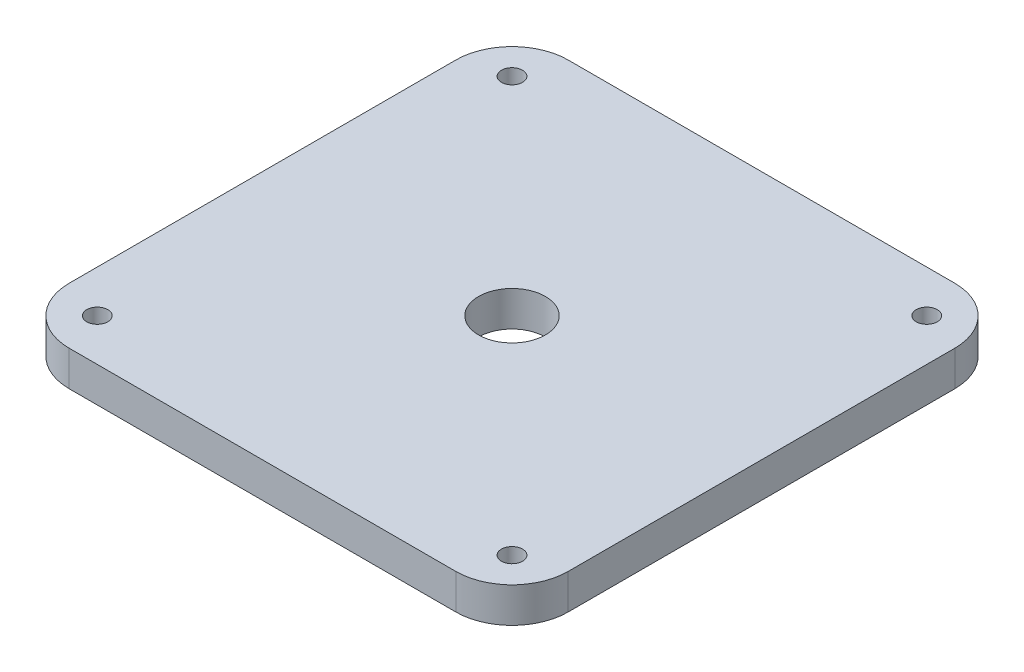
from build123d import *

# Parameters (mm, degrees)
SKETCH1_W           = 71
SKETCH1_H           = 71
SKETCH1_R           = 1.5
SKETCH1_R_2         = 4.75
BOSS_EXTRUDE1_DEPTH = 5
FILLET1_R           = 8


with BuildPart() as part:
    # Sketch1 → Boss-Extrude1 (new body)
    with BuildSketch(Plane(origin=(0, 0, 0), x_dir=(1, 0, 0), z_dir=(0, 1, 0))):
        with Locations((35.5, 35.5)):
            Rectangle(SKETCH1_W, SKETCH1_H)
        with Locations((6, 6)):
            Circle(SKETCH1_R, mode=Mode.SUBTRACT)
        with Locations((65, 6)):
            Circle(SKETCH1_R, mode=Mode.SUBTRACT)
        with Locations((65, 65)):
            Circle(SKETCH1_R, mode=Mode.SUBTRACT)
        with Locations((6, 65)):
            Circle(SKETCH1_R, mode=Mode.SUBTRACT)
        with Locations((35.5, 35.5)):
            Circle(SKETCH1_R_2, mode=Mode.SUBTRACT)
    extrude(amount=BOSS_EXTRUDE1_DEPTH)

    # Fillet1
    fillet1_edges = [part.edges().sort_by_distance(p)[0] for p in [
        (0, 2.5, -71),
        (71, 2.5, -71),
        (71, 2.5, 0),
        (0, 2.5, 0),
    ]]
    fillet(fillet1_edges, radius=FILLET1_R)


solid = part.part
